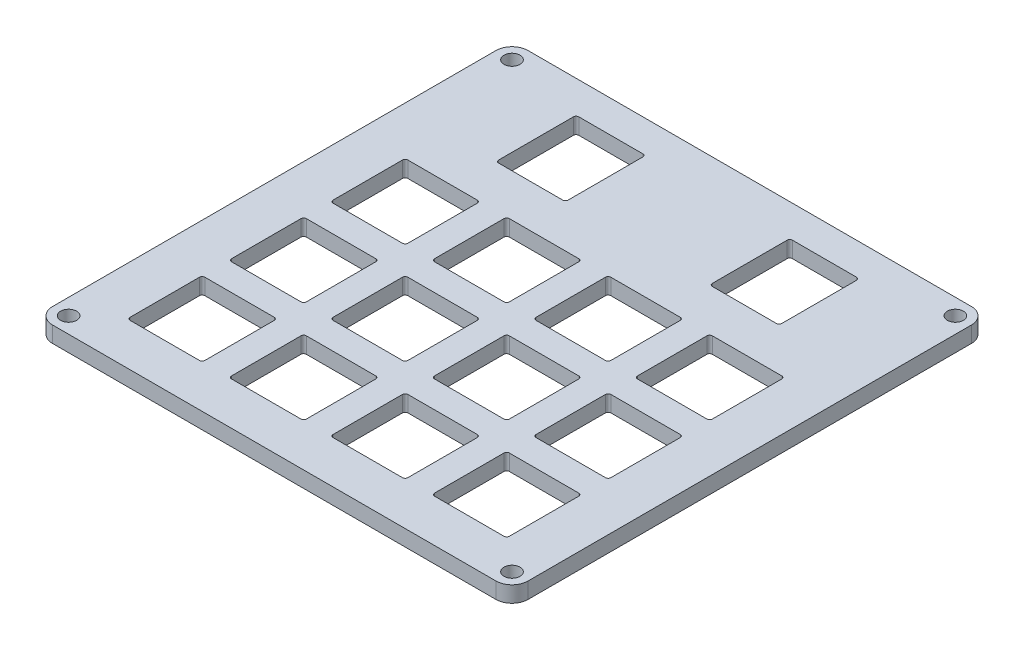
from build123d import *

# Parameters (mm, degrees)
SKETCH1_R           = 1.5
BOSS_EXTRUDE1_DEPTH = 3


with BuildPart() as part:
    # Sketch1 → Boss-Extrude1 (new body)
    with BuildSketch(Plane(origin=(0, 0, 0), x_dir=(1, 0, 0), z_dir=(0, 1, 0))):
        with BuildLine():
            Line((-41.5, -44.5), (41.5, -44.5))
            ThreePointArc((41.5, -44.5), (43.621320344, -43.621320344), (44.5, -41.5))
            Line((44.5, -41.5), (44.5, 41.5))
            ThreePointArc((44.5, 41.5), (43.621320344, 43.621320344), (41.5, 44.5))
            Line((41.5, 44.5), (-41.5, 44.5))
            ThreePointArc((-41.5, 44.5), (-43.621320344, 43.621320344), (-44.5, 41.5))
            Line((-44.5, 41.5), (-44.5, -41.5))
            ThreePointArc((-44.5, -41.5), (-43.621320344, -43.621320344), (-41.5, -44.5))
        make_face()
        with Locations((-41.5, 41.5)):
            Circle(SKETCH1_R, mode=Mode.SUBTRACT)
        with Locations((41.5, 41.5)):
            Circle(SKETCH1_R, mode=Mode.SUBTRACT)
        with Locations((41.5, -41.5)):
            Circle(SKETCH1_R, mode=Mode.SUBTRACT)
        with Locations((-41.5, -41.5)):
            Circle(SKETCH1_R, mode=Mode.SUBTRACT)
        with BuildLine():
            Line((26, 23.5), (14, 23.5))
            ThreePointArc((14, 23.5), (13.646446609, 23.646446609), (13.5, 24))
            Line((13.5, 24), (13.5, 38))
            ThreePointArc((13.5, 38), (13.646446609, 38.353553391), (14, 38.5))
            Line((14, 38.5), (26, 38.5))
            ThreePointArc((26, 38.5), (26.353553391, 38.353553391), (26.5, 38))
            Line((26.5, 38), (26.5, 24))
            ThreePointArc((26.5, 24), (26.353553391, 23.646446609), (26, 23.5))
        make_face(mode=Mode.SUBTRACT)
        with BuildLine():
            Line((-16.5, -36), (-16.5, -23))
            ThreePointArc((-16.5, -23), (-16.353553391, -22.646446609), (-16, -22.5))
            Line((-16, -22.5), (-3, -22.5))
            ThreePointArc((-3, -22.5), (-2.646446609, -22.646446609), (-2.5, -23))
            Line((-2.5, -23), (-2.5, -36))
            ThreePointArc((-2.5, -36), (-2.646446609, -36.353553391), (-3, -36.5))
            Line((-3, -36.5), (-16, -36.5))
            ThreePointArc((-16, -36.5), (-16.353553391, -36.353553391), (-16.5, -36))
        make_face(mode=Mode.SUBTRACT)
        with BuildLine():
            Line((-35, -36.5), (-22, -36.5))
            ThreePointArc((-22, -36.5), (-21.646446609, -36.353553391), (-21.5, -36))
            Line((-21.5, -36), (-21.5, -23))
            ThreePointArc((-21.5, -23), (-21.646446609, -22.646446609), (-22, -22.5))
            Line((-22, -22.5), (-35, -22.5))
            ThreePointArc((-35, -22.5), (-35.353553391, -22.646446609), (-35.5, -23))
            Line((-35.5, -23), (-35.5, -36))
            ThreePointArc((-35.5, -36), (-35.353553391, -36.353553391), (-35, -36.5))
        make_face(mode=Mode.SUBTRACT)
        with BuildLine():
            Line((2.5, -36), (2.5, -23))
            ThreePointArc((2.5, -23), (2.646446609, -22.646446609), (3, -22.5))
            Line((3, -22.5), (16, -22.5))
            ThreePointArc((16, -22.5), (16.353553391, -22.646446609), (16.5, -23))
            Line((16.5, -23), (16.5, -36))
            ThreePointArc((16.5, -36), (16.353553391, -36.353553391), (16, -36.5))
            Line((16, -36.5), (3, -36.5))
            ThreePointArc((3, -36.5), (2.646446609, -36.353553391), (2.5, -36))
        make_face(mode=Mode.SUBTRACT)
        with BuildLine():
            Line((21.5, -36), (21.5, -23))
            ThreePointArc((21.5, -23), (21.646446609, -22.646446609), (22, -22.5))
            Line((22, -22.5), (35, -22.5))
            ThreePointArc((35, -22.5), (35.353553391, -22.646446609), (35.5, -23))
            Line((35.5, -23), (35.5, -36))
            ThreePointArc((35.5, -36), (35.353553391, -36.353553391), (35, -36.5))
            Line((35, -36.5), (22, -36.5))
            ThreePointArc((22, -36.5), (21.646446609, -36.353553391), (21.5, -36))
        make_face(mode=Mode.SUBTRACT)
        with BuildLine():
            Line((-16.5, -17), (-16.5, -4))
            ThreePointArc((-16.5, -4), (-16.353553391, -3.646446609), (-16, -3.5))
            Line((-16, -3.5), (-3, -3.5))
            ThreePointArc((-3, -3.5), (-2.646446609, -3.646446609), (-2.5, -4))
            Line((-2.5, -4), (-2.5, -17))
            ThreePointArc((-2.5, -17), (-2.646446609, -17.353553391), (-3, -17.5))
            Line((-3, -17.5), (-16, -17.5))
            ThreePointArc((-16, -17.5), (-16.353553391, -17.353553391), (-16.5, -17))
        make_face(mode=Mode.SUBTRACT)
        with BuildLine():
            Line((2.5, -17), (2.5, -4))
            ThreePointArc((2.5, -4), (2.646446609, -3.646446609), (3, -3.5))
            Line((3, -3.5), (16, -3.5))
            ThreePointArc((16, -3.5), (16.353553391, -3.646446609), (16.5, -4))
            Line((16.5, -4), (16.5, -17))
            ThreePointArc((16.5, -17), (16.353553391, -17.353553391), (16, -17.5))
            Line((16, -17.5), (3, -17.5))
            ThreePointArc((3, -17.5), (2.646446609, -17.353553391), (2.5, -17))
        make_face(mode=Mode.SUBTRACT)
        with BuildLine():
            Line((21.5, -17), (21.5, -4))
            ThreePointArc((21.5, -4), (21.646446609, -3.646446609), (22, -3.5))
            Line((22, -3.5), (35, -3.5))
            ThreePointArc((35, -3.5), (35.353553391, -3.646446609), (35.5, -4))
            Line((35.5, -4), (35.5, -17))
            ThreePointArc((35.5, -17), (35.353553391, -17.353553391), (35, -17.5))
            Line((35, -17.5), (22, -17.5))
            ThreePointArc((22, -17.5), (21.646446609, -17.353553391), (21.5, -17))
        make_face(mode=Mode.SUBTRACT)
        with BuildLine():
            Line((-16.5, 2), (-16.5, 15))
            ThreePointArc((-16.5, 15), (-16.353553391, 15.353553391), (-16, 15.5))
            Line((-16, 15.5), (-3, 15.5))
            ThreePointArc((-3, 15.5), (-2.646446609, 15.353553391), (-2.5, 15))
            Line((-2.5, 15), (-2.5, 2))
            ThreePointArc((-2.5, 2), (-2.646446609, 1.646446609), (-3, 1.5))
            Line((-3, 1.5), (-16, 1.5))
            ThreePointArc((-16, 1.5), (-16.353553391, 1.646446609), (-16.5, 2))
        make_face(mode=Mode.SUBTRACT)
        with BuildLine():
            Line((2.5, 2), (2.5, 15))
            ThreePointArc((2.5, 15), (2.646446609, 15.353553391), (3, 15.5))
            Line((3, 15.5), (16, 15.5))
            ThreePointArc((16, 15.5), (16.353553391, 15.353553391), (16.5, 15))
            Line((16.5, 15), (16.5, 2))
            ThreePointArc((16.5, 2), (16.353553391, 1.646446609), (16, 1.5))
            Line((16, 1.5), (3, 1.5))
            ThreePointArc((3, 1.5), (2.646446609, 1.646446609), (2.5, 2))
        make_face(mode=Mode.SUBTRACT)
        with BuildLine():
            Line((21.5, 2), (21.5, 15))
            ThreePointArc((21.5, 15), (21.646446609, 15.353553391), (22, 15.5))
            Line((22, 15.5), (35, 15.5))
            ThreePointArc((35, 15.5), (35.353553391, 15.353553391), (35.5, 15))
            Line((35.5, 15), (35.5, 2))
            ThreePointArc((35.5, 2), (35.353553391, 1.646446609), (35, 1.5))
            Line((35, 1.5), (22, 1.5))
            ThreePointArc((22, 1.5), (21.646446609, 1.646446609), (21.5, 2))
        make_face(mode=Mode.SUBTRACT)
        with BuildLine():
            Line((-35.5, -17), (-35.5, -4))
            ThreePointArc((-35.5, -4), (-35.353553391, -3.646446609), (-35, -3.5))
            Line((-35, -3.5), (-22, -3.5))
            ThreePointArc((-22, -3.5), (-21.646446609, -3.646446609), (-21.5, -4))
            Line((-21.5, -4), (-21.5, -17))
            ThreePointArc((-21.5, -17), (-21.646446609, -17.353553391), (-22, -17.5))
            Line((-22, -17.5), (-35, -17.5))
            ThreePointArc((-35, -17.5), (-35.353553391, -17.353553391), (-35.5, -17))
        make_face(mode=Mode.SUBTRACT)
        with BuildLine():
            Line((-35.5, 2), (-35.5, 15))
            ThreePointArc((-35.5, 15), (-35.353553391, 15.353553391), (-35, 15.5))
            Line((-35, 15.5), (-22, 15.5))
            ThreePointArc((-22, 15.5), (-21.646446609, 15.353553391), (-21.5, 15))
            Line((-21.5, 15), (-21.5, 2))
            ThreePointArc((-21.5, 2), (-21.646446609, 1.646446609), (-22, 1.5))
            Line((-22, 1.5), (-35, 1.5))
            ThreePointArc((-35, 1.5), (-35.353553391, 1.646446609), (-35.5, 2))
        make_face(mode=Mode.SUBTRACT)
        with BuildLine():
            Line((-26, 38.5), (-14, 38.5))
            ThreePointArc((-14, 38.5), (-13.646446609, 38.353553391), (-13.5, 38))
            Line((-13.5, 38), (-13.5, 24))
            ThreePointArc((-13.5, 24), (-13.646446609, 23.646446609), (-14, 23.5))
            Line((-14, 23.5), (-26, 23.5))
            ThreePointArc((-26, 23.5), (-26.353553391, 23.646446609), (-26.5, 24))
            Line((-26.5, 24), (-26.5, 38))
            ThreePointArc((-26.5, 38), (-26.353553391, 38.353553391), (-26, 38.5))
        make_face(mode=Mode.SUBTRACT)
    extrude(amount=BOSS_EXTRUDE1_DEPTH)


solid = part.part
